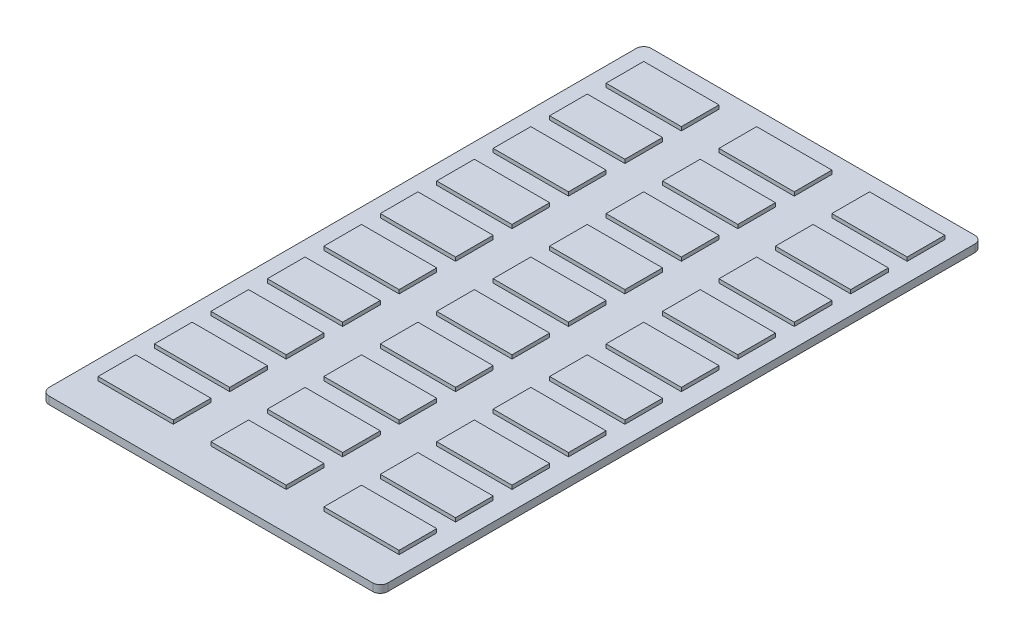
from build123d import *

# Parameters (mm, degrees)
SKETCH1_W           = 90
SKETCH1_H           = 160
BOSS_EXTRUDE1_DEPTH = 2
SKETCH2_W           = 20
SKETCH2_H           = 10
BOSS_EXTRUDE2_DEPTH = 1
LPATTERN1_COUNT     = 3
LPATTERN1_PITCH     = 30
FILLET1_R           = 2


with BuildPart() as part:
    # Sketch1 → Boss-Extrude1 (new body)
    with BuildSketch(Plane(origin=(0, 0, 0), x_dir=(1, 0, 0), z_dir=(0, 1, 0))):
        Rectangle(SKETCH1_W, SKETCH1_H)
    extrude(amount=BOSS_EXTRUDE1_DEPTH)

    # Sketch2 → Boss-Extrude2 (add)
    with BuildSketch(Plane(origin=(0, 2, 0), x_dir=(1, 0, 0), z_dir=(0, 1, 0))):
        with Locations((-30, 70)):
            Rectangle(SKETCH2_W, SKETCH2_H)
        with Locations((-30, 55)):
            Rectangle(SKETCH2_W, SKETCH2_H)
        with Locations((-30, 40)):
            Rectangle(SKETCH2_W, SKETCH2_H)
        with Locations((-30, 25)):
            Rectangle(SKETCH2_W, SKETCH2_H)
        with Locations((-30, 10)):
            Rectangle(SKETCH2_W, SKETCH2_H)
        with Locations((-30, -5)):
            Rectangle(SKETCH2_W, SKETCH2_H)
        with Locations((-30, -20)):
            Rectangle(SKETCH2_W, SKETCH2_H)
        with Locations((-30, -35)):
            Rectangle(SKETCH2_W, SKETCH2_H)
        with Locations((-30, -50)):
            Rectangle(SKETCH2_W, SKETCH2_H)
        with Locations((-30, -65)):
            Rectangle(SKETCH2_W, SKETCH2_H)
    boss_extrude2 = extrude(amount=BOSS_EXTRUDE2_DEPTH)

    # LPattern1: Boss-Extrude2 ×3
    with Locations(*[(i * LPATTERN1_PITCH, 0, 0) for i in range(1, LPATTERN1_COUNT)]):
        add(boss_extrude2)

    # Fillet1
    fillet1_edges = [part.edges().sort_by_distance(p)[0] for p in [
        (-45, 1, -80),
        (45, 1, -80),
        (45, 1, 80),
        (-45, 1, 80),
    ]]
    fillet(fillet1_edges, radius=FILLET1_R)


solid = part.part
